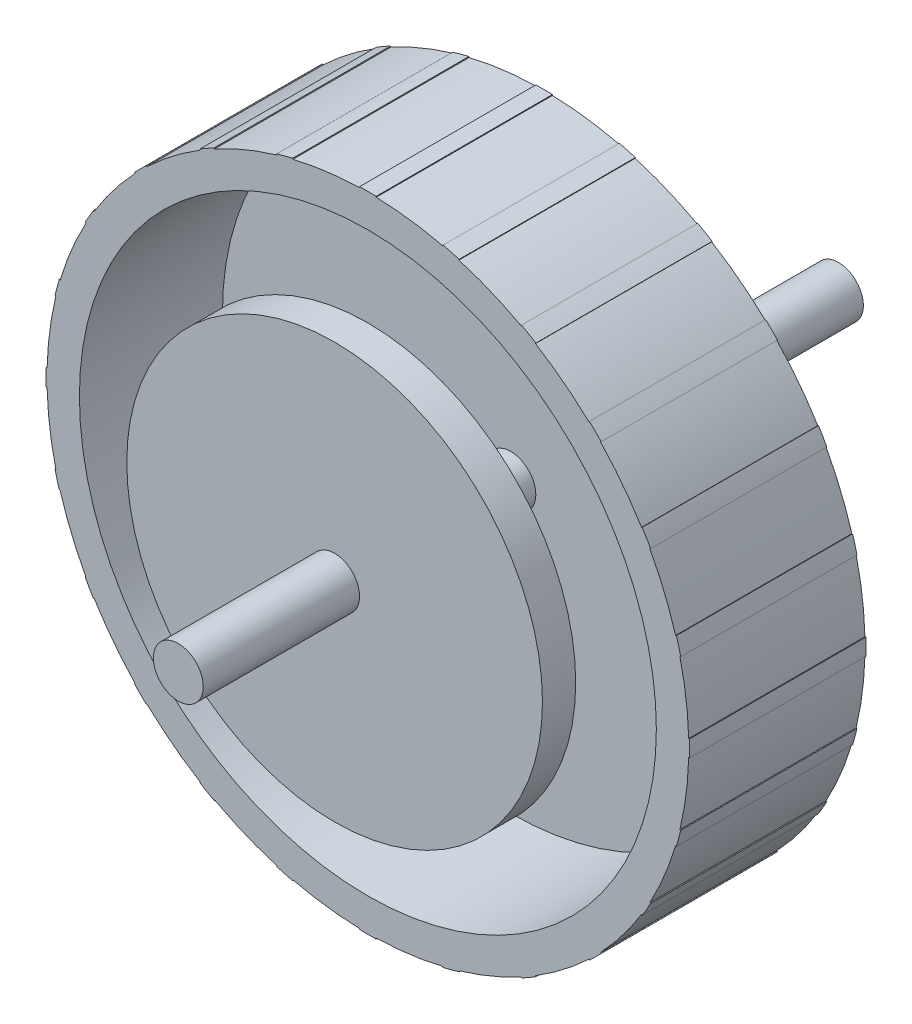
from build123d import *

# Parameters (mm, degrees)
SKETCH1_R           = 19.3
BOSS_EXTRUDE1_DEPTH = 10.6
BOSS_EXTRUDE3_DEPTH = 10.6
SKETCH8_R           = 17.35
CUT_EXTRUDE2_DEPTH  = 8.6
CIRPATTERN1_COUNT   = 24
BOSS_EXTRUDE4_DEPTH = 9.7
CUT_EXTRUDE1_DEPTH  = 11.6
BOSS_EXTRUDE5_DEPTH = 0.1
CIRPATTERN2_COUNT   = 3
SKETCH10_R          = 1.5
BOSS_EXTRUDE6_DEPTH = 20
SKETCH11_R          = 12.5
BOSS_EXTRUDE7_DEPTH = 2


with BuildPart() as part:
    # Sketch1 → Boss-Extrude1 (new body)
    with BuildSketch(Plane.XY):
        Circle(SKETCH1_R)
    extrude(amount=BOSS_EXTRUDE1_DEPTH)

    # Sketch3 → Boss-Extrude3 (add, through all)
    with BuildSketch(Plane.XY.offset(10.6)):
        with BuildLine():
            Line((-0.5, 19.343538973), (-0.49870801, 19.293555668))
            ThreePointArc((-0.49870801, 19.293555668), (0, 19.3), (0.49870801, 19.293555668))
            Line((0.49870801, 19.293555668), (0.5, 19.343538973))
            ThreePointArc((0.5, 19.343538973), (0, 19.35), (-0.5, 19.343538973))
        make_face()
    boss_extrude3 = extrude(amount=-BOSS_EXTRUDE3_DEPTH)

    # Sketch8 → Cut-Extrude2 (cut)
    with BuildSketch(Plane.XY.offset(10.6)):
        Circle(SKETCH8_R)
    extrude(amount=-CUT_EXTRUDE2_DEPTH, mode=Mode.SUBTRACT)

    # CirPattern1: Boss-Extrude3 ×24 about axis
    cirpattern1_axis = Axis((0, 0, 0), (0, 0, 1))
    for i in range(1, CIRPATTERN1_COUNT):
        add(boss_extrude3.rotate(cirpattern1_axis, i * 360 / CIRPATTERN1_COUNT))

    # Sketch5 → Revolve1 (revolve)
    with BuildSketch(Plane(origin=(0, 0, 0), x_dir=(1, 0, 0), z_dir=(0, 1, 0))):
        Polygon((0, 0), (4, 0), (2.95, 1.05), (2.95, 8), (0, 8), align=None)
    revolve(axis=Axis((0, 0, -8), (0, 0, 1)))

    # Sketch6 → Boss-Extrude4 (add)
    with BuildSketch(Plane(origin=(0, 0, -8), x_dir=(-1, 0, 0), z_dir=(0, 0, -1))):
        with BuildLine():
            Line((0.95, 1.160818677), (0.95, -1.160818677))
            ThreePointArc((0.95, -1.160818677), (-1.5, 0), (0.95, 1.160818677))
        make_face()
    extrude(amount=BOSS_EXTRUDE4_DEPTH)

    # Sketch7 → Cut-Extrude1 (cut, through all)
    with BuildSketch(Plane(origin=(0, 0, 0), x_dir=(-1, 0, 0), z_dir=(0, 0, -1))):
        with BuildLine():
            Line((1.14141791, 16.059488322), (0.95, 13.366282206))
            ThreePointArc((0.95, 13.366282206), (2.191173704, 13.219635313), (3.413286083, 12.957988969))
            Line((3.413286083, 12.957988969), (4.101037757, 15.568927045))
            ThreePointArc((4.101037757, 15.568927045), (2.632678854, 15.883293174), (1.14141791, 16.059488322))
        make_face()
    cut_extrude1 = extrude(amount=-CUT_EXTRUDE1_DEPTH, mode=Mode.SUBTRACT)

    # Sketch9 → Boss-Extrude5 (add)
    with BuildSketch(Plane(origin=(0, 0, 0), x_dir=(-1, 0, 0), z_dir=(0, 0, -1))):
        with BuildLine():
            Line((4.101037757, 15.568927045), (3.413286083, 12.957988969))
            ThreePointArc((3.413286083, 12.957988969), (3.814061699, 12.845735999), (4.211157884, 12.721090727))
            ThreePointArc((4.211157884, 12.721090727), (5.917018752, 13.578434707), (5.059674771, 15.284295574))
            Line((5.059674771, 15.284295574), (4.101037757, 15.568927045))
        make_face()
    boss_extrude5 = extrude(amount=BOSS_EXTRUDE5_DEPTH)

    # CirPattern2: Cut-Extrude1, Boss-Extrude5 ×3 about axis
    cirpattern2_axis = Axis((0, 0, 0), (0, 0, 1))
    for i in range(1, CIRPATTERN2_COUNT):
        add(cut_extrude1.rotate(cirpattern2_axis, i * 360 / CIRPATTERN2_COUNT), mode=Mode.SUBTRACT)
        add(boss_extrude5.rotate(cirpattern2_axis, i * 360 / CIRPATTERN2_COUNT))

    # Sketch10 → Boss-Extrude6 (add)
    with BuildSketch(Plane.XY.offset(2)):
        Circle(SKETCH10_R)
    extrude(amount=BOSS_EXTRUDE6_DEPTH)

    # Sketch11 → Boss-Extrude7 (add)
    with BuildSketch(Plane.XY.offset(10.6)):
        Circle(SKETCH11_R)
    extrude(amount=BOSS_EXTRUDE7_DEPTH)


solid = part.part
